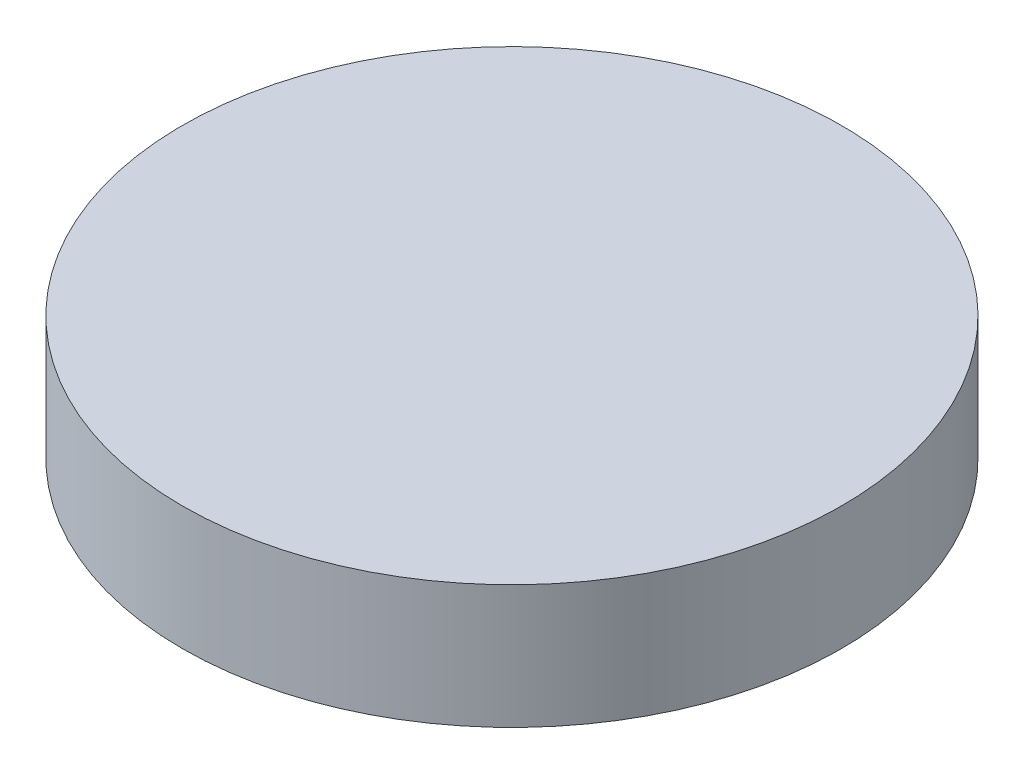
from build123d import *

# Parameters (mm, degrees)
SKETCH1_R           = 8
BOSS_EXTRUDE1_DEPTH = 3


with BuildPart() as part:
    # Sketch1 → Boss-Extrude1 (new body)
    with BuildSketch(Plane(origin=(0, 0, 0), x_dir=(1, 0, 0), z_dir=(0, 1, 0))):
        Circle(SKETCH1_R)
    extrude(amount=BOSS_EXTRUDE1_DEPTH)


solid = part.part
